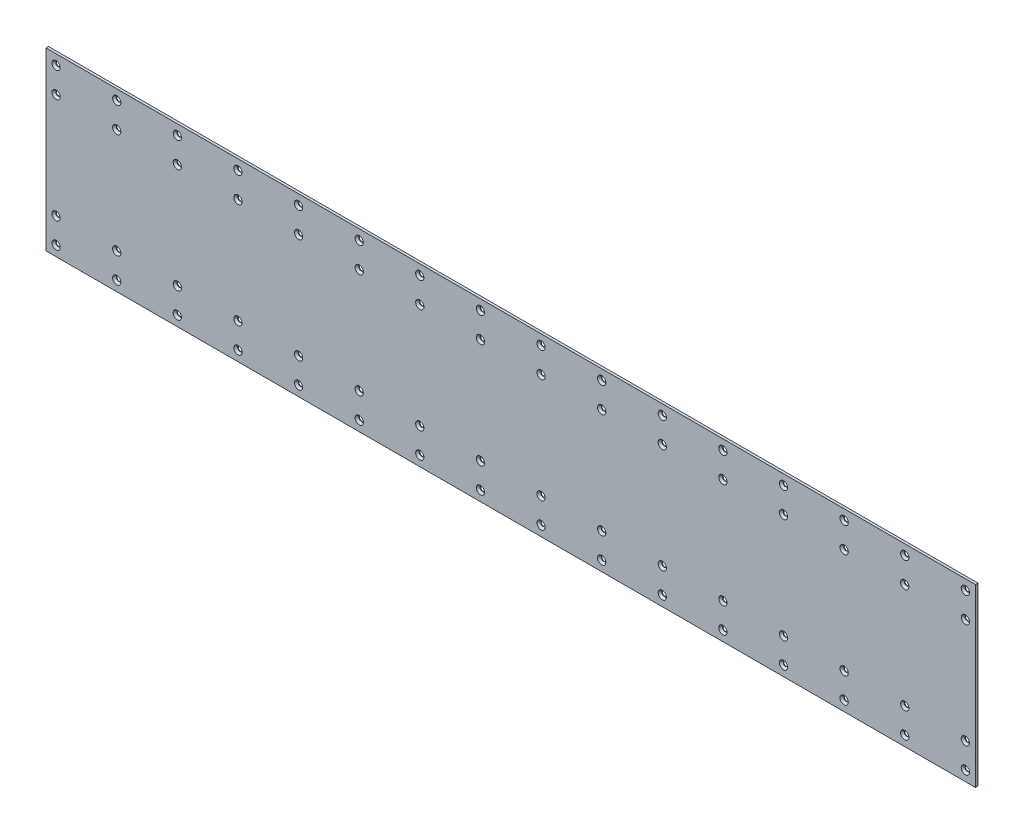
from build123d import *

# Parameters (mm, degrees)
SKETCH1_W                                 = 1168.4
SKETCH1_H                                 = 220.98
BOSS_EXTRUDE1_DEPTH                       = 3.175
CSK_FOR_0_FLAT_HEAD_MACHINE_SCREW_2_COUNT = 2
CSK_FOR_0_FLAT_HEAD_MACHINE_SCREW_2_PITCH = 31.75
CSK_FOR_0_FLAT_HEAD_MACHINE_SCREW_3_COUNT = 2
CSK_FOR_0_FLAT_HEAD_MACHINE_SCREW_3_PITCH = 163.83
CSK_FOR_0_FLAT_HEAD_MACHINE_SCREW_4_COUNT = 2
CSK_FOR_0_FLAT_HEAD_MACHINE_SCREW_4_PITCH = 195.58
LPATTERN1_COUNT                           = 16
LPATTERN1_PITCH                           = 76.2


with BuildPart() as part:
    # Sketch1 → Boss-Extrude1 (new body)
    with BuildSketch(Plane.XY):
        with Locations((584.2, 110.49)):
            Rectangle(SKETCH1_W, SKETCH1_H)
    extrude(amount=-BOSS_EXTRUDE1_DEPTH)

    # Sketch3 → CSK for #0 Flat Head Machine Screw (100)1 (revolve, cut)
    with BuildSketch(Plane(origin=(12.7, 208.28, 0), x_dir=(0, -1, 0), z_dir=(1, 0, 0))):
        Polygon((0, 0), (0, 3.175), (2.7559, 3.175), (2.7559, 2.4384), (5.1943, 0), align=None)
    csk_for_0_flat_head_machine_screw_100 = revolve(axis=Axis((12.7, 208.28, 6.35), (0, 0, -1)), mode=Mode.SUBTRACT)

    # CSK for _0 Flat Head Machine Screw _ 2: CSK for #0 Flat Head Machine Screw (100)1 ×2
    with Locations(*[(0, -i * CSK_FOR_0_FLAT_HEAD_MACHINE_SCREW_2_PITCH, 0) for i in range(1, CSK_FOR_0_FLAT_HEAD_MACHINE_SCREW_2_COUNT)]):
        add(csk_for_0_flat_head_machine_screw_100, mode=Mode.SUBTRACT)

    # CSK for _0 Flat Head Machine Screw _ 3: CSK for #0 Flat Head Machine Screw (100)1 ×2
    with Locations(*[(0, -i * CSK_FOR_0_FLAT_HEAD_MACHINE_SCREW_3_PITCH, 0) for i in range(1, CSK_FOR_0_FLAT_HEAD_MACHINE_SCREW_3_COUNT)]):
        add(csk_for_0_flat_head_machine_screw_100, mode=Mode.SUBTRACT)

    # CSK for _0 Flat Head Machine Screw _ 4: CSK for #0 Flat Head Machine Screw (100)1 ×2
    with Locations(*[(0, -i * CSK_FOR_0_FLAT_HEAD_MACHINE_SCREW_4_PITCH, 0) for i in range(1, CSK_FOR_0_FLAT_HEAD_MACHINE_SCREW_4_COUNT)]):
        add(csk_for_0_flat_head_machine_screw_100, mode=Mode.SUBTRACT)

    # LPattern1: CSK for #0 Flat Head Machine Screw (100)1 ×16
    with Locations(*[(i * LPATTERN1_PITCH, 0, 0) for i in range(1, LPATTERN1_COUNT)]):
        add(csk_for_0_flat_head_machine_screw_100, mode=Mode.SUBTRACT)

    # LPattern1 copy 1 sketch → LPattern1 copy 1 (revolve, cut)
    with BuildSketch(Plane(origin=(88.9, 176.53, 0), x_dir=(0, -1, 0), z_dir=(1, 0, 0))):
        Polygon((0, 0), (0, 3.175), (2.7559, 3.175), (2.7559, 2.4384), (5.1943, 0), align=None)
    revolve(axis=Axis((88.9, 176.53, 6.35), (0, 0, -1)), mode=Mode.SUBTRACT)

    # LPattern1 copy 2 sketch → LPattern1 copy 2 (revolve, cut)
    with BuildSketch(Plane(origin=(165.1, 176.53, 0), x_dir=(0, -1, 0), z_dir=(1, 0, 0))):
        Polygon((0, 0), (0, 3.175), (2.7559, 3.175), (2.7559, 2.4384), (5.1943, 0), align=None)
    revolve(axis=Axis((165.1, 176.53, 6.35), (0, 0, -1)), mode=Mode.SUBTRACT)

    # LPattern1 copy 3 sketch → LPattern1 copy 3 (revolve, cut)
    with BuildSketch(Plane(origin=(241.3, 176.53, 0), x_dir=(0, -1, 0), z_dir=(1, 0, 0))):
        Polygon((0, 0), (0, 3.175), (2.7559, 3.175), (2.7559, 2.4384), (5.1943, 0), align=None)
    revolve(axis=Axis((241.3, 176.53, 6.35), (0, 0, -1)), mode=Mode.SUBTRACT)

    # LPattern1 copy 4 sketch → LPattern1 copy 4 (revolve, cut)
    with BuildSketch(Plane(origin=(317.5, 176.53, 0), x_dir=(0, -1, 0), z_dir=(1, 0, 0))):
        Polygon((0, 0), (0, 3.175), (2.7559, 3.175), (2.7559, 2.4384), (5.1943, 0), align=None)
    revolve(axis=Axis((317.5, 176.53, 6.35), (0, 0, -1)), mode=Mode.SUBTRACT)

    # LPattern1 copy 5 sketch → LPattern1 copy 5 (revolve, cut)
    with BuildSketch(Plane(origin=(393.7, 176.53, 0), x_dir=(0, -1, 0), z_dir=(1, 0, 0))):
        Polygon((0, 0), (0, 3.175), (2.7559, 3.175), (2.7559, 2.4384), (5.1943, 0), align=None)
    revolve(axis=Axis((393.7, 176.53, 6.35), (0, 0, -1)), mode=Mode.SUBTRACT)

    # LPattern1 copy 6 sketch → LPattern1 copy 6 (revolve, cut)
    with BuildSketch(Plane(origin=(469.9, 176.53, 0), x_dir=(0, -1, 0), z_dir=(1, 0, 0))):
        Polygon((0, 0), (0, 3.175), (2.7559, 3.175), (2.7559, 2.4384), (5.1943, 0), align=None)
    revolve(axis=Axis((469.9, 176.53, 6.35), (0, 0, -1)), mode=Mode.SUBTRACT)

    # LPattern1 copy 7 sketch → LPattern1 copy 7 (revolve, cut)
    with BuildSketch(Plane(origin=(546.1, 176.53, 0), x_dir=(0, -1, 0), z_dir=(1, 0, 0))):
        Polygon((0, 0), (0, 3.175), (2.7559, 3.175), (2.7559, 2.4384), (5.1943, 0), align=None)
    revolve(axis=Axis((546.1, 176.53, 6.35), (0, 0, -1)), mode=Mode.SUBTRACT)

    # LPattern1 copy 8 sketch → LPattern1 copy 8 (revolve, cut)
    with BuildSketch(Plane(origin=(622.3, 176.53, 0), x_dir=(0, -1, 0), z_dir=(1, 0, 0))):
        Polygon((0, 0), (0, 3.175), (2.7559, 3.175), (2.7559, 2.4384), (5.1943, 0), align=None)
    revolve(axis=Axis((622.3, 176.53, 6.35), (0, 0, -1)), mode=Mode.SUBTRACT)

    # LPattern1 copy 9 sketch → LPattern1 copy 9 (revolve, cut)
    with BuildSketch(Plane(origin=(698.5, 176.53, 0), x_dir=(0, -1, 0), z_dir=(1, 0, 0))):
        Polygon((0, 0), (0, 3.175), (2.7559, 3.175), (2.7559, 2.4384), (5.1943, 0), align=None)
    revolve(axis=Axis((698.5, 176.53, 6.35), (0, 0, -1)), mode=Mode.SUBTRACT)

    # LPattern1 copy 10 sketch → LPattern1 copy 10 (revolve, cut)
    with BuildSketch(Plane(origin=(774.7, 176.53, 0), x_dir=(0, -1, 0), z_dir=(1, 0, 0))):
        Polygon((0, 0), (0, 3.175), (2.7559, 3.175), (2.7559, 2.4384), (5.1943, 0), align=None)
    revolve(axis=Axis((774.7, 176.53, 6.35), (0, 0, -1)), mode=Mode.SUBTRACT)

    # LPattern1 copy 11 sketch → LPattern1 copy 11 (revolve, cut)
    with BuildSketch(Plane(origin=(850.9, 176.53, 0), x_dir=(0, -1, 0), z_dir=(1, 0, 0))):
        Polygon((0, 0), (0, 3.175), (2.7559, 3.175), (2.7559, 2.4384), (5.1943, 0), align=None)
    revolve(axis=Axis((850.9, 176.53, 6.35), (0, 0, -1)), mode=Mode.SUBTRACT)

    # LPattern1 copy 12 sketch → LPattern1 copy 12 (revolve, cut)
    with BuildSketch(Plane(origin=(927.1, 176.53, 0), x_dir=(0, -1, 0), z_dir=(1, 0, 0))):
        Polygon((0, 0), (0, 3.175), (2.7559, 3.175), (2.7559, 2.4384), (5.1943, 0), align=None)
    revolve(axis=Axis((927.1, 176.53, 6.35), (0, 0, -1)), mode=Mode.SUBTRACT)

    # LPattern1 copy 13 sketch → LPattern1 copy 13 (revolve, cut)
    with BuildSketch(Plane(origin=(1003.3, 176.53, 0), x_dir=(0, -1, 0), z_dir=(1, 0, 0))):
        Polygon((0, 0), (0, 3.175), (2.7559, 3.175), (2.7559, 2.4384), (5.1943, 0), align=None)
    revolve(axis=Axis((1003.3, 176.53, 6.35), (0, 0, -1)), mode=Mode.SUBTRACT)

    # LPattern1 copy 14 sketch → LPattern1 copy 14 (revolve, cut)
    with BuildSketch(Plane(origin=(1079.5, 176.53, 0), x_dir=(0, -1, 0), z_dir=(1, 0, 0))):
        Polygon((0, 0), (0, 3.175), (2.7559, 3.175), (2.7559, 2.4384), (5.1943, 0), align=None)
    revolve(axis=Axis((1079.5, 176.53, 6.35), (0, 0, -1)), mode=Mode.SUBTRACT)

    # LPattern1 copy 15 sketch → LPattern1 copy 15 (revolve, cut)
    with BuildSketch(Plane(origin=(1155.7, 176.53, 0), x_dir=(0, -1, 0), z_dir=(1, 0, 0))):
        Polygon((0, 0), (0, 3.175), (2.7559, 3.175), (2.7559, 2.4384), (5.1943, 0), align=None)
    revolve(axis=Axis((1155.7, 176.53, 6.35), (0, 0, -1)), mode=Mode.SUBTRACT)

    # LPattern1 copy 16 sketch → LPattern1 copy 16 (revolve, cut)
    with BuildSketch(Plane(origin=(88.9, 44.45, 0), x_dir=(0, -1, 0), z_dir=(1, 0, 0))):
        Polygon((0, 0), (0, 3.175), (2.7559, 3.175), (2.7559, 2.4384), (5.1943, 0), align=None)
    revolve(axis=Axis((88.9, 44.45, 6.35), (0, 0, -1)), mode=Mode.SUBTRACT)

    # LPattern1 copy 17 sketch → LPattern1 copy 17 (revolve, cut)
    with BuildSketch(Plane(origin=(165.1, 44.45, 0), x_dir=(0, -1, 0), z_dir=(1, 0, 0))):
        Polygon((0, 0), (0, 3.175), (2.7559, 3.175), (2.7559, 2.4384), (5.1943, 0), align=None)
    revolve(axis=Axis((165.1, 44.45, 6.35), (0, 0, -1)), mode=Mode.SUBTRACT)

    # LPattern1 copy 18 sketch → LPattern1 copy 18 (revolve, cut)
    with BuildSketch(Plane(origin=(241.3, 44.45, 0), x_dir=(0, -1, 0), z_dir=(1, 0, 0))):
        Polygon((0, 0), (0, 3.175), (2.7559, 3.175), (2.7559, 2.4384), (5.1943, 0), align=None)
    revolve(axis=Axis((241.3, 44.45, 6.35), (0, 0, -1)), mode=Mode.SUBTRACT)

    # LPattern1 copy 19 sketch → LPattern1 copy 19 (revolve, cut)
    with BuildSketch(Plane(origin=(317.5, 44.45, 0), x_dir=(0, -1, 0), z_dir=(1, 0, 0))):
        Polygon((0, 0), (0, 3.175), (2.7559, 3.175), (2.7559, 2.4384), (5.1943, 0), align=None)
    revolve(axis=Axis((317.5, 44.45, 6.35), (0, 0, -1)), mode=Mode.SUBTRACT)

    # LPattern1 copy 20 sketch → LPattern1 copy 20 (revolve, cut)
    with BuildSketch(Plane(origin=(393.7, 44.45, 0), x_dir=(0, -1, 0), z_dir=(1, 0, 0))):
        Polygon((0, 0), (0, 3.175), (2.7559, 3.175), (2.7559, 2.4384), (5.1943, 0), align=None)
    revolve(axis=Axis((393.7, 44.45, 6.35), (0, 0, -1)), mode=Mode.SUBTRACT)

    # LPattern1 copy 21 sketch → LPattern1 copy 21 (revolve, cut)
    with BuildSketch(Plane(origin=(469.9, 44.45, 0), x_dir=(0, -1, 0), z_dir=(1, 0, 0))):
        Polygon((0, 0), (0, 3.175), (2.7559, 3.175), (2.7559, 2.4384), (5.1943, 0), align=None)
    revolve(axis=Axis((469.9, 44.45, 6.35), (0, 0, -1)), mode=Mode.SUBTRACT)

    # LPattern1 copy 22 sketch → LPattern1 copy 22 (revolve, cut)
    with BuildSketch(Plane(origin=(546.1, 44.45, 0), x_dir=(0, -1, 0), z_dir=(1, 0, 0))):
        Polygon((0, 0), (0, 3.175), (2.7559, 3.175), (2.7559, 2.4384), (5.1943, 0), align=None)
    revolve(axis=Axis((546.1, 44.45, 6.35), (0, 0, -1)), mode=Mode.SUBTRACT)

    # LPattern1 copy 23 sketch → LPattern1 copy 23 (revolve, cut)
    with BuildSketch(Plane(origin=(622.3, 44.45, 0), x_dir=(0, -1, 0), z_dir=(1, 0, 0))):
        Polygon((0, 0), (0, 3.175), (2.7559, 3.175), (2.7559, 2.4384), (5.1943, 0), align=None)
    revolve(axis=Axis((622.3, 44.45, 6.35), (0, 0, -1)), mode=Mode.SUBTRACT)

    # LPattern1 copy 24 sketch → LPattern1 copy 24 (revolve, cut)
    with BuildSketch(Plane(origin=(698.5, 44.45, 0), x_dir=(0, -1, 0), z_dir=(1, 0, 0))):
        Polygon((0, 0), (0, 3.175), (2.7559, 3.175), (2.7559, 2.4384), (5.1943, 0), align=None)
    revolve(axis=Axis((698.5, 44.45, 6.35), (0, 0, -1)), mode=Mode.SUBTRACT)

    # LPattern1 copy 25 sketch → LPattern1 copy 25 (revolve, cut)
    with BuildSketch(Plane(origin=(774.7, 44.45, 0), x_dir=(0, -1, 0), z_dir=(1, 0, 0))):
        Polygon((0, 0), (0, 3.175), (2.7559, 3.175), (2.7559, 2.4384), (5.1943, 0), align=None)
    revolve(axis=Axis((774.7, 44.45, 6.35), (0, 0, -1)), mode=Mode.SUBTRACT)

    # LPattern1 copy 26 sketch → LPattern1 copy 26 (revolve, cut)
    with BuildSketch(Plane(origin=(850.9, 44.45, 0), x_dir=(0, -1, 0), z_dir=(1, 0, 0))):
        Polygon((0, 0), (0, 3.175), (2.7559, 3.175), (2.7559, 2.4384), (5.1943, 0), align=None)
    revolve(axis=Axis((850.9, 44.45, 6.35), (0, 0, -1)), mode=Mode.SUBTRACT)

    # LPattern1 copy 27 sketch → LPattern1 copy 27 (revolve, cut)
    with BuildSketch(Plane(origin=(927.1, 44.45, 0), x_dir=(0, -1, 0), z_dir=(1, 0, 0))):
        Polygon((0, 0), (0, 3.175), (2.7559, 3.175), (2.7559, 2.4384), (5.1943, 0), align=None)
    revolve(axis=Axis((927.1, 44.45, 6.35), (0, 0, -1)), mode=Mode.SUBTRACT)

    # LPattern1 copy 28 sketch → LPattern1 copy 28 (revolve, cut)
    with BuildSketch(Plane(origin=(1003.3, 44.45, 0), x_dir=(0, -1, 0), z_dir=(1, 0, 0))):
        Polygon((0, 0), (0, 3.175), (2.7559, 3.175), (2.7559, 2.4384), (5.1943, 0), align=None)
    revolve(axis=Axis((1003.3, 44.45, 6.35), (0, 0, -1)), mode=Mode.SUBTRACT)

    # LPattern1 copy 29 sketch → LPattern1 copy 29 (revolve, cut)
    with BuildSketch(Plane(origin=(1079.5, 44.45, 0), x_dir=(0, -1, 0), z_dir=(1, 0, 0))):
        Polygon((0, 0), (0, 3.175), (2.7559, 3.175), (2.7559, 2.4384), (5.1943, 0), align=None)
    revolve(axis=Axis((1079.5, 44.45, 6.35), (0, 0, -1)), mode=Mode.SUBTRACT)

    # LPattern1 copy 30 sketch → LPattern1 copy 30 (revolve, cut)
    with BuildSketch(Plane(origin=(1155.7, 44.45, 0), x_dir=(0, -1, 0), z_dir=(1, 0, 0))):
        Polygon((0, 0), (0, 3.175), (2.7559, 3.175), (2.7559, 2.4384), (5.1943, 0), align=None)
    revolve(axis=Axis((1155.7, 44.45, 6.35), (0, 0, -1)), mode=Mode.SUBTRACT)

    # LPattern1 copy 31 sketch → LPattern1 copy 31 (revolve, cut)
    with BuildSketch(Plane(origin=(88.9, 12.7, 0), x_dir=(0, -1, 0), z_dir=(1, 0, 0))):
        Polygon((0, 0), (0, 3.175), (2.7559, 3.175), (2.7559, 2.4384), (5.1943, 0), align=None)
    revolve(axis=Axis((88.9, 12.7, 6.35), (0, 0, -1)), mode=Mode.SUBTRACT)

    # LPattern1 copy 32 sketch → LPattern1 copy 32 (revolve, cut)
    with BuildSketch(Plane(origin=(165.1, 12.7, 0), x_dir=(0, -1, 0), z_dir=(1, 0, 0))):
        Polygon((0, 0), (0, 3.175), (2.7559, 3.175), (2.7559, 2.4384), (5.1943, 0), align=None)
    revolve(axis=Axis((165.1, 12.7, 6.35), (0, 0, -1)), mode=Mode.SUBTRACT)

    # LPattern1 copy 33 sketch → LPattern1 copy 33 (revolve, cut)
    with BuildSketch(Plane(origin=(241.3, 12.7, 0), x_dir=(0, -1, 0), z_dir=(1, 0, 0))):
        Polygon((0, 0), (0, 3.175), (2.7559, 3.175), (2.7559, 2.4384), (5.1943, 0), align=None)
    revolve(axis=Axis((241.3, 12.7, 6.35), (0, 0, -1)), mode=Mode.SUBTRACT)

    # LPattern1 copy 34 sketch → LPattern1 copy 34 (revolve, cut)
    with BuildSketch(Plane(origin=(317.5, 12.7, 0), x_dir=(0, -1, 0), z_dir=(1, 0, 0))):
        Polygon((0, 0), (0, 3.175), (2.7559, 3.175), (2.7559, 2.4384), (5.1943, 0), align=None)
    revolve(axis=Axis((317.5, 12.7, 6.35), (0, 0, -1)), mode=Mode.SUBTRACT)

    # LPattern1 copy 35 sketch → LPattern1 copy 35 (revolve, cut)
    with BuildSketch(Plane(origin=(393.7, 12.7, 0), x_dir=(0, -1, 0), z_dir=(1, 0, 0))):
        Polygon((0, 0), (0, 3.175), (2.7559, 3.175), (2.7559, 2.4384), (5.1943, 0), align=None)
    revolve(axis=Axis((393.7, 12.7, 6.35), (0, 0, -1)), mode=Mode.SUBTRACT)

    # LPattern1 copy 36 sketch → LPattern1 copy 36 (revolve, cut)
    with BuildSketch(Plane(origin=(469.9, 12.7, 0), x_dir=(0, -1, 0), z_dir=(1, 0, 0))):
        Polygon((0, 0), (0, 3.175), (2.7559, 3.175), (2.7559, 2.4384), (5.1943, 0), align=None)
    revolve(axis=Axis((469.9, 12.7, 6.35), (0, 0, -1)), mode=Mode.SUBTRACT)

    # LPattern1 copy 37 sketch → LPattern1 copy 37 (revolve, cut)
    with BuildSketch(Plane(origin=(546.1, 12.7, 0), x_dir=(0, -1, 0), z_dir=(1, 0, 0))):
        Polygon((0, 0), (0, 3.175), (2.7559, 3.175), (2.7559, 2.4384), (5.1943, 0), align=None)
    revolve(axis=Axis((546.1, 12.7, 6.35), (0, 0, -1)), mode=Mode.SUBTRACT)

    # LPattern1 copy 38 sketch → LPattern1 copy 38 (revolve, cut)
    with BuildSketch(Plane(origin=(622.3, 12.7, 0), x_dir=(0, -1, 0), z_dir=(1, 0, 0))):
        Polygon((0, 0), (0, 3.175), (2.7559, 3.175), (2.7559, 2.4384), (5.1943, 0), align=None)
    revolve(axis=Axis((622.3, 12.7, 6.35), (0, 0, -1)), mode=Mode.SUBTRACT)

    # LPattern1 copy 39 sketch → LPattern1 copy 39 (revolve, cut)
    with BuildSketch(Plane(origin=(698.5, 12.7, 0), x_dir=(0, -1, 0), z_dir=(1, 0, 0))):
        Polygon((0, 0), (0, 3.175), (2.7559, 3.175), (2.7559, 2.4384), (5.1943, 0), align=None)
    revolve(axis=Axis((698.5, 12.7, 6.35), (0, 0, -1)), mode=Mode.SUBTRACT)

    # LPattern1 copy 40 sketch → LPattern1 copy 40 (revolve, cut)
    with BuildSketch(Plane(origin=(774.7, 12.7, 0), x_dir=(0, -1, 0), z_dir=(1, 0, 0))):
        Polygon((0, 0), (0, 3.175), (2.7559, 3.175), (2.7559, 2.4384), (5.1943, 0), align=None)
    revolve(axis=Axis((774.7, 12.7, 6.35), (0, 0, -1)), mode=Mode.SUBTRACT)

    # LPattern1 copy 41 sketch → LPattern1 copy 41 (revolve, cut)
    with BuildSketch(Plane(origin=(850.9, 12.7, 0), x_dir=(0, -1, 0), z_dir=(1, 0, 0))):
        Polygon((0, 0), (0, 3.175), (2.7559, 3.175), (2.7559, 2.4384), (5.1943, 0), align=None)
    revolve(axis=Axis((850.9, 12.7, 6.35), (0, 0, -1)), mode=Mode.SUBTRACT)

    # LPattern1 copy 42 sketch → LPattern1 copy 42 (revolve, cut)
    with BuildSketch(Plane(origin=(927.1, 12.7, 0), x_dir=(0, -1, 0), z_dir=(1, 0, 0))):
        Polygon((0, 0), (0, 3.175), (2.7559, 3.175), (2.7559, 2.4384), (5.1943, 0), align=None)
    revolve(axis=Axis((927.1, 12.7, 6.35), (0, 0, -1)), mode=Mode.SUBTRACT)

    # LPattern1 copy 43 sketch → LPattern1 copy 43 (revolve, cut)
    with BuildSketch(Plane(origin=(1003.3, 12.7, 0), x_dir=(0, -1, 0), z_dir=(1, 0, 0))):
        Polygon((0, 0), (0, 3.175), (2.7559, 3.175), (2.7559, 2.4384), (5.1943, 0), align=None)
    revolve(axis=Axis((1003.3, 12.7, 6.35), (0, 0, -1)), mode=Mode.SUBTRACT)

    # LPattern1 copy 44 sketch → LPattern1 copy 44 (revolve, cut)
    with BuildSketch(Plane(origin=(1079.5, 12.7, 0), x_dir=(0, -1, 0), z_dir=(1, 0, 0))):
        Polygon((0, 0), (0, 3.175), (2.7559, 3.175), (2.7559, 2.4384), (5.1943, 0), align=None)
    revolve(axis=Axis((1079.5, 12.7, 6.35), (0, 0, -1)), mode=Mode.SUBTRACT)

    # LPattern1 copy 45 sketch → LPattern1 copy 45 (revolve, cut)
    with BuildSketch(Plane(origin=(1155.7, 12.7, 0), x_dir=(0, -1, 0), z_dir=(1, 0, 0))):
        Polygon((0, 0), (0, 3.175), (2.7559, 3.175), (2.7559, 2.4384), (5.1943, 0), align=None)
    revolve(axis=Axis((1155.7, 12.7, 6.35), (0, 0, -1)), mode=Mode.SUBTRACT)


solid = part.part
